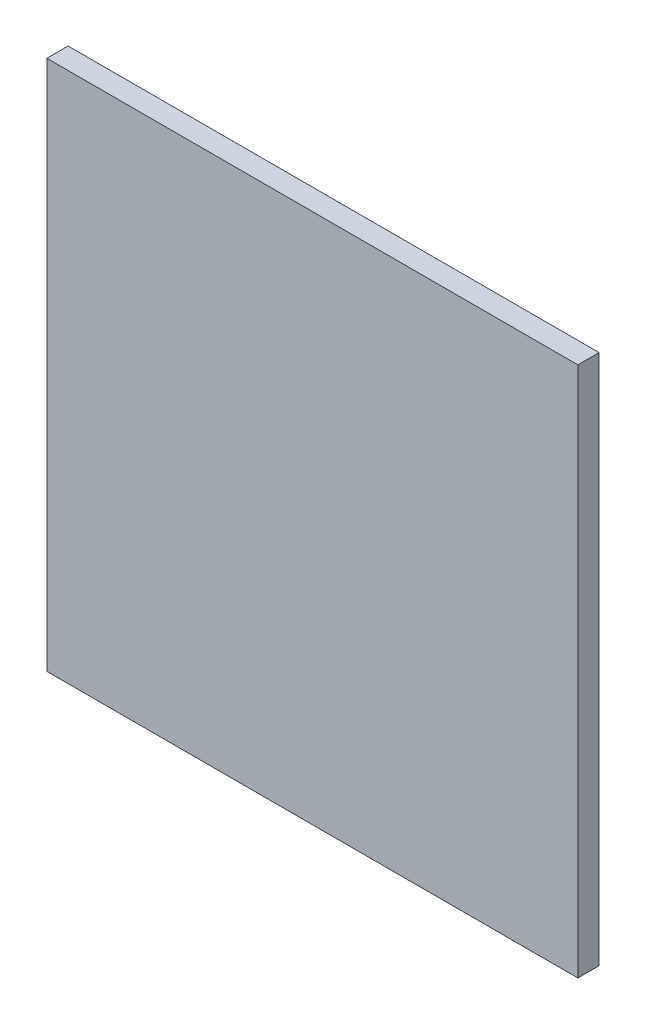
from build123d import *

# Parameters (mm, degrees)
SKIZZE1_W                       = 500
SKIZZE1_H                       = 500
AUFSATZ_LINEAR_AUSTRAGEN1_DEPTH = 20


with BuildPart() as part:
    # Skizze1 → Aufsatz-Linear austragen1 (new body)
    with BuildSketch(Plane.XY):
        Rectangle(SKIZZE1_W, SKIZZE1_H)
    extrude(amount=AUFSATZ_LINEAR_AUSTRAGEN1_DEPTH)


solid = part.part
